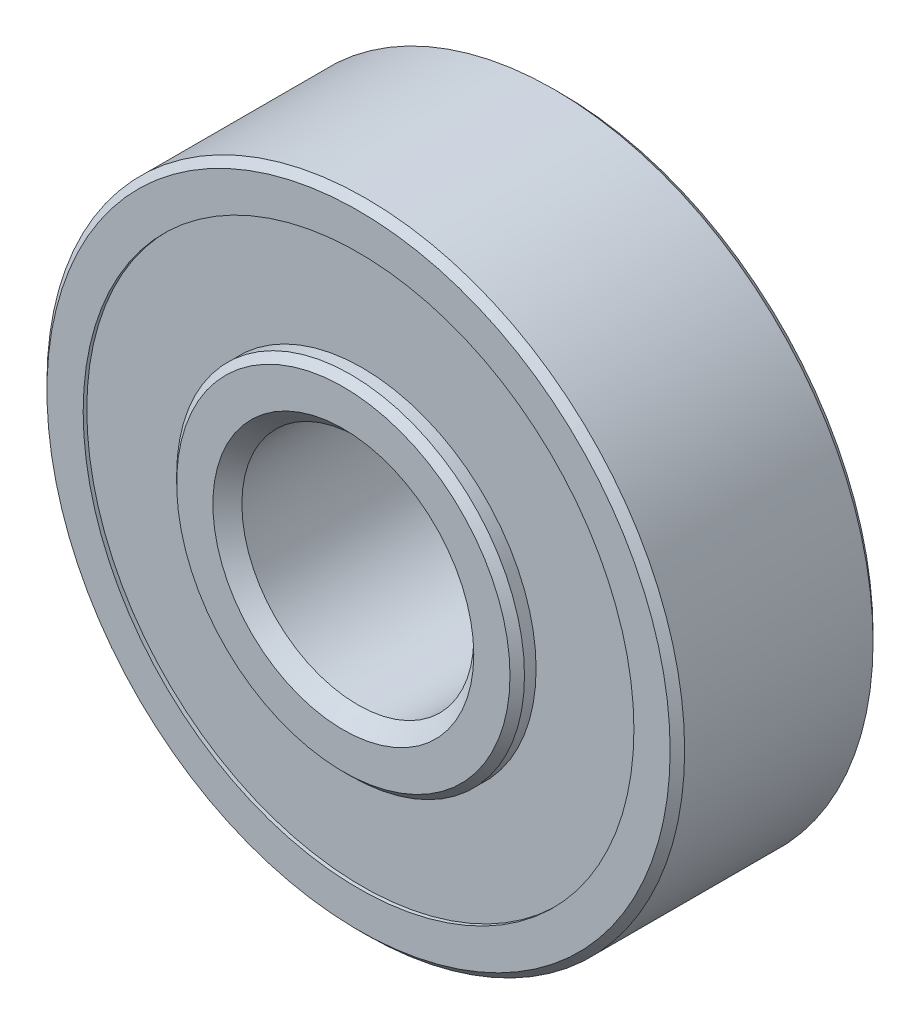
from build123d import *

# Parameters (mm, degrees)
SKETCH1_R           = 11
SKETCH1_R_2         = 9.5
BOSS_EXTRUDE1_DEPTH = 3.5
SKETCH1_4_R         = 6
SKETCH1_4_R_2       = 4
BOSS_EXTRUDE2_DEPTH = 4.025
SKETCH1_5_R         = 9.5
SKETCH1_5_R_2       = 6
BOSS_EXTRUDE3_DEPTH = 3.375
CHAMFER1_SIZE       = 0.5
CHAMFER2_SIZE       = 0.25


with BuildPart() as part:
    # Sketch1 → Boss-Extrude1 (new, symmetric)
    with BuildSketch(Plane.XY):
        Circle(SKETCH1_R)
        Circle(SKETCH1_R_2, mode=Mode.SUBTRACT)
    extrude(amount=BOSS_EXTRUDE1_DEPTH, both=True)



with BuildPart() as body_2:
    # Sketch1_4 → Boss-Extrude2 (new, symmetric)
    with BuildSketch(Plane.XY):
        Circle(SKETCH1_4_R)
        Circle(SKETCH1_4_R_2, mode=Mode.SUBTRACT)
    extrude(amount=BOSS_EXTRUDE2_DEPTH, both=True)


with BuildPart() as part_1:
    add(part.part)

    add(body_2.part)  # Boss-Extrude3 merges body 2
    # Sketch1_5 → Boss-Extrude3 (add, symmetric)
    with BuildSketch(Plane.XY):
        Circle(SKETCH1_5_R)
        Circle(SKETCH1_5_R_2, mode=Mode.SUBTRACT)
    extrude(amount=BOSS_EXTRUDE3_DEPTH, both=True)

    # Chamfer1
    chamfer1_edges = [part_1.edges().sort_by_distance(p)[0] for p in [
        (-4, 0, -4.025),
        (-4, 0, 4.025),
    ]]
    chamfer(chamfer1_edges, length=CHAMFER1_SIZE)

    # Chamfer2
    chamfer2_edges = [part_1.edges().sort_by_distance(p)[0] for p in [
        (-11, 0, -3.5),
        (-11, 0, 3.5),
        (-6, 0, 4.025),
        (-6, 0, -4.025),
    ]]
    chamfer(chamfer2_edges, length=CHAMFER2_SIZE)


solid = part_1.part
